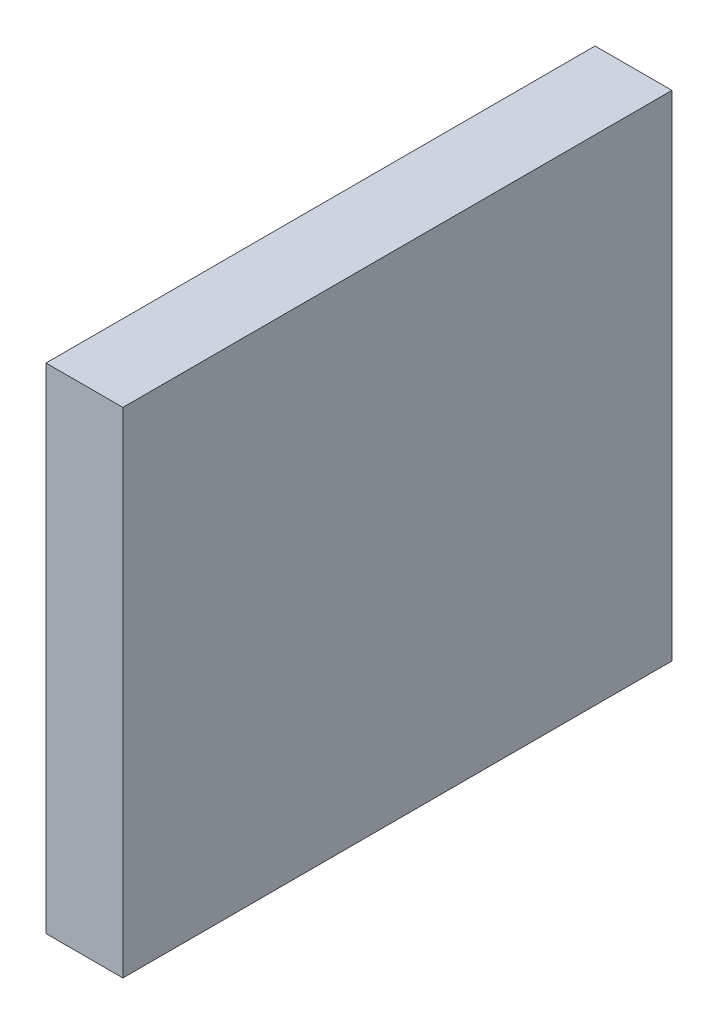
from build123d import *

# Parameters (mm, degrees)
SKETCH1_W           = 50
SKETCH1_H           = 45
BOSS_EXTRUDE1_DEPTH = 7


with BuildPart() as part:
    # Sketch1 → Boss-Extrude1 (new body)
    with BuildSketch(Plane(origin=(0, 0, 0), x_dir=(0, 0, -1), z_dir=(1, 0, 0))):
        with Locations((25, 22.5)):
            Rectangle(SKETCH1_W, SKETCH1_H)
    extrude(amount=BOSS_EXTRUDE1_DEPTH)


solid = part.part
